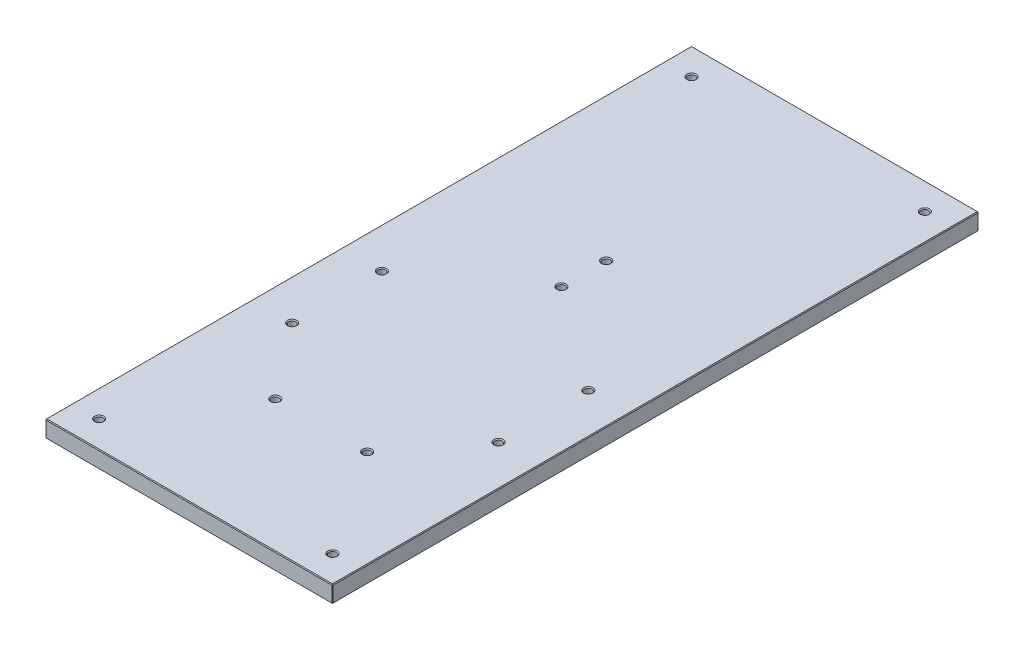
from build123d import *

# Parameters (mm, degrees)
SKETCH1_W                           = 203.2
SKETCH1_H                           = 457.2
BOSS_EXTRUDE1_DEPTH                 = 6
F_4_0_209_DIAMETER_HOLE1_AT_2_COUNT = 2
F_4_0_209_DIAMETER_HOLE1_AT_2_PITCH = 165.1
F_4_0_209_DIAMETER_HOLE1_AT_3_COUNT = 2
F_4_0_209_DIAMETER_HOLE1_AT_3_PITCH = 450.447355415
F_4_0_209_DIAMETER_HOLE1_AT_4_COUNT = 2
F_4_0_209_DIAMETER_HOLE1_AT_4_PITCH = 419.1
CHAMFER1_SIZE                       = 0.508
F_4_0_209_DIAMETER_HOLE3_AT_2_COUNT = 2
F_4_0_209_DIAMETER_HOLE3_AT_2_PITCH = 65
F_4_0_209_DIAMETER_HOLE3_AT_3_COUNT = 2
F_4_0_209_DIAMETER_HOLE3_AT_3_PITCH = 173.005073986
F_4_0_209_DIAMETER_HOLE3_AT_4_COUNT = 2
F_4_0_209_DIAMETER_HOLE3_AT_4_PITCH = 204.276909182
F_4_0_209_DIAMETER_HOLE3_AT_5_COUNT = 2
F_4_0_209_DIAMETER_HOLE3_AT_5_PITCH = 122.827839373
F_4_0_209_DIAMETER_HOLE3_AT_6_COUNT = 2
F_4_0_209_DIAMETER_HOLE3_AT_6_PITCH = 66.281808402
F_4_0_209_DIAMETER_HOLE3_AT_7_COUNT = 2
F_4_0_209_DIAMETER_HOLE3_AT_7_PITCH = 117.841113899
F_4_0_209_DIAMETER_HOLE3_AT_8_COUNT = 2
F_4_0_209_DIAMETER_HOLE3_AT_8_PITCH = 156.779871556


with BuildPart() as part:
    # Sketch1 → Boss-Extrude1 (new, symmetric)
    with BuildSketch(Plane(origin=(0, 0, 0), x_dir=(1, 0, 0), z_dir=(0, 1, 0))):
        Rectangle(SKETCH1_W, SKETCH1_H)
    extrude(amount=BOSS_EXTRUDE1_DEPTH, both=True)

    # Sketch4 → 4 _0.209_ Diameter Hole1 (revolve, cut)
    with BuildSketch(Plane(origin=(-82.55, 6, -209.55), x_dir=(0, 0, 1), z_dir=(1, 0, 0))):
        Polygon((0, 0), (0, 12), (3.2893, 12), (2.6543, 11.365), (2.6543, 0.635), (3.2893, 0), align=None)
    f_4_0_209_diameter_hole1 = revolve(axis=Axis((-82.55, 12.35, -209.55), (0, -1, 0)), mode=Mode.SUBTRACT)

    # 4 _0.209_ Diameter Hole1 at 2: 4 _0.209_ Diameter Hole1 ×2
    with Locations(*[(i * F_4_0_209_DIAMETER_HOLE1_AT_2_PITCH, 0, 0) for i in range(1, F_4_0_209_DIAMETER_HOLE1_AT_2_COUNT)]):
        add(f_4_0_209_diameter_hole1, mode=Mode.SUBTRACT)

    # 4 _0.209_ Diameter Hole1 at 3: 4 _0.209_ Diameter Hole1 ×2
    with Locations(*[Vector(0.36652451838249067, 0, 0.9304083928170915) * (i * F_4_0_209_DIAMETER_HOLE1_AT_3_PITCH) for i in range(1, F_4_0_209_DIAMETER_HOLE1_AT_3_COUNT)]):
        add(f_4_0_209_diameter_hole1, mode=Mode.SUBTRACT)

    # 4 _0.209_ Diameter Hole1 at 4: 4 _0.209_ Diameter Hole1 ×2
    with Locations(*[(0, 0, i * F_4_0_209_DIAMETER_HOLE1_AT_4_PITCH) for i in range(1, F_4_0_209_DIAMETER_HOLE1_AT_4_COUNT)]):
        add(f_4_0_209_diameter_hole1, mode=Mode.SUBTRACT)

    # Chamfer1
    chamfer1_edges = [part.edges().sort_by_distance(p)[0] for p in [
        (101.6, 6, 0),
        (101.6, -6, 0),
        (101.6, 0, -228.6),
        (0, 6, -228.6),
        (0, -6, -228.6),
        (-101.6, 0, -228.6),
        (-101.6, 6, 0),
        (-101.6, -6, 0),
        (-101.6, 0, 228.6),
        (0, 6, 228.6),
        (101.6, 0, 228.6),
        (0, -6, 228.6),
    ]]
    chamfer(chamfer1_edges, length=CHAMFER1_SIZE)

    # Sketch11 → 4 _0.209_ Diameter Hole3 (revolve, cut)
    with BuildSketch(Plane(origin=(-32.5, 6, 135), x_dir=(0, 0, 1), z_dir=(1, 0, 0))):
        Polygon((0, 0), (0, 12), (3.2893, 12), (2.6543, 11.365), (2.6543, 0.635), (3.2893, 0), align=None)
    f_4_0_209_diameter_hole3 = revolve(axis=Axis((-32.5, 12.35, 135), (0, -1, 0)), mode=Mode.SUBTRACT)

    # 4 _0.209_ Diameter Hole3 at 2: 4 _0.209_ Diameter Hole3 ×2
    with Locations(*[(i * F_4_0_209_DIAMETER_HOLE3_AT_2_PITCH, 0, 0) for i in range(1, F_4_0_209_DIAMETER_HOLE3_AT_2_COUNT)]):
        add(f_4_0_209_diameter_hole3, mode=Mode.SUBTRACT)

    # 4 _0.209_ Diameter Hole3 at 3: 4 _0.209_ Diameter Hole3 ×2
    with Locations(*[Vector(0.1878557619794241, 0, -0.9821966262877968) * (i * F_4_0_209_DIAMETER_HOLE3_AT_3_PITCH) for i in range(1, F_4_0_209_DIAMETER_HOLE3_AT_3_COUNT)]):
        add(f_4_0_209_diameter_hole3, mode=Mode.SUBTRACT)

    # 4 _0.209_ Diameter Hole3 at 4: 4 _0.209_ Diameter Hole3 ×2
    with Locations(*[Vector(0.15909776650784052, 0, -0.9872628326298001) * (i * F_4_0_209_DIAMETER_HOLE3_AT_4_PITCH) for i in range(1, F_4_0_209_DIAMETER_HOLE3_AT_4_COUNT)]):
        add(f_4_0_209_diameter_hole3, mode=Mode.SUBTRACT)

    # 4 _0.209_ Diameter Hole3 at 5: 4 _0.209_ Diameter Hole3 ×2
    with Locations(*[Vector(-0.3299333457864378, 0, -0.9440042305721765) * (i * F_4_0_209_DIAMETER_HOLE3_AT_5_PITCH) for i in range(1, F_4_0_209_DIAMETER_HOLE3_AT_5_COUNT)]):
        add(f_4_0_209_diameter_hole3, mode=Mode.SUBTRACT)

    # 4 _0.209_ Diameter Hole3 at 6: 4 _0.209_ Diameter Hole3 ×2
    with Locations(*[Vector(-0.6114045614808405, 0, -0.7913181801275775) * (i * F_4_0_209_DIAMETER_HOLE3_AT_6_PITCH) for i in range(1, F_4_0_209_DIAMETER_HOLE3_AT_6_COUNT)]):
        add(f_4_0_209_diameter_hole3, mode=Mode.SUBTRACT)

    # 4 _0.209_ Diameter Hole3 at 7: 4 _0.209_ Diameter Hole3 ×2
    with Locations(*[Vector(0.8954854253183739, 0, -0.4450908368438638) * (i * F_4_0_209_DIAMETER_HOLE3_AT_7_PITCH) for i in range(1, F_4_0_209_DIAMETER_HOLE3_AT_7_COUNT)]):
        add(f_4_0_209_diameter_hole3, mode=Mode.SUBTRACT)

    # 4 _0.209_ Diameter Hole3 at 8: 4 _0.209_ Diameter Hole3 ×2
    with Locations(*[Vector(0.6730774745057522, 0, -0.7395719798051835) * (i * F_4_0_209_DIAMETER_HOLE3_AT_8_PITCH) for i in range(1, F_4_0_209_DIAMETER_HOLE3_AT_8_COUNT)]):
        add(f_4_0_209_diameter_hole3, mode=Mode.SUBTRACT)


solid = part.part
